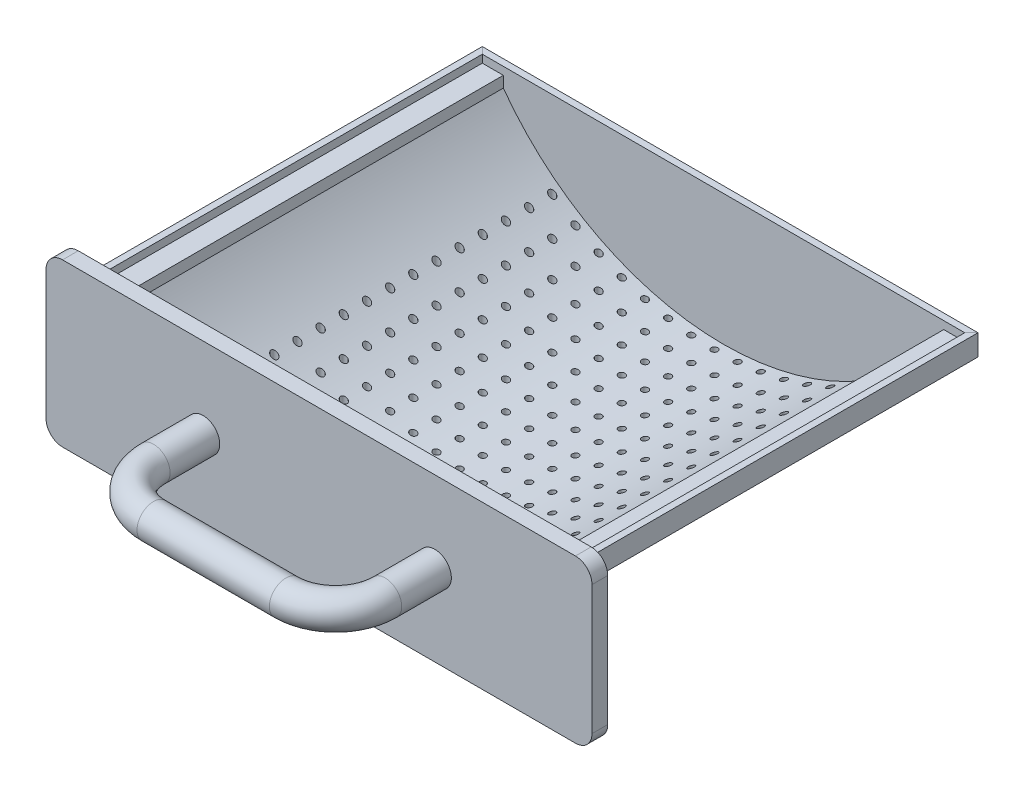
from build123d import *

# Parameters (mm, degrees)
RESSALTO_EXTRUS_O1_DEPTH = 4.75
ESBO_O2_R                = 5
ESBO_O8_W                = 137.1
ESBO_O8_H                = 4.35
CORTE_EXTRUS_O1_DEPTH    = 40.65
RESSALTO_EXTRUS_O3_DEPTH = 119.5
RESSALTO_EXTRUS_O4_DEPTH = 2
ESBO_O11_R               = 1
CORTE_EXTRUS_O2_DEPTH    = 25.5


with BuildPart() as part:
    # Esboço1 → Ressalto-extrusão1 (new body)
    with BuildSketch(Plane.XY):
        with BuildLine():
            Line((77.5, -24.5), (-77.5, -24.5))
            ThreePointArc((-77.5, -24.5), (-81.035533906, -23.035533906), (-82.5, -19.5))
            Line((-82.5, -19.5), (-82.5, 19.5))
            ThreePointArc((-82.5, 19.5), (-81.035533906, 23.035533906), (-77.5, 24.5))
            Line((-77.5, 24.5), (77.5, 24.5))
            ThreePointArc((77.5, 24.5), (81.035533906, 23.035533906), (82.5, 19.5))
            Line((82.5, 19.5), (82.5, -19.5))
            ThreePointArc((82.5, -19.5), (81.035533906, -23.035533906), (77.5, -24.5))
        make_face()
    extrude(amount=RESSALTO_EXTRUS_O1_DEPTH)

    # Varredura1: sweep along a path in Esboço3
    with BuildLine(Plane(origin=(0, 0, 0), x_dir=(1, 0, 0), z_dir=(0, 1, 0))) as varredura1_path:
        Line((-35, -4.75), (-35, -19.75))
        ThreePointArc((-35, -19.75), (-30.606601718, -30.356601718), (-20, -34.75))
        Line((-20, -34.75), (20, -34.75))
        ThreePointArc((20, -34.75), (30.606601718, -30.356601718), (35, -19.75))
        Line((35, -19.75), (35, -4.75))
    # Esboço2 → Varredura1 (sweep)
    with BuildSketch(Plane.XY.offset(4.75)):
        with Locations((-35, 0)):
            Circle(ESBO_O2_R)
    sweep(path=varredura1_path.line)

    # Varredura2: sweep along a path in Esboço6
    with BuildLine(Plane(origin=(0, 0, 0), x_dir=(1, 0, 0), z_dir=(0, 1, 0))) as varredura2_path:
        Line((74, 0), (74, 118.6))
        Line((74, 118.6), (-74, 118.6))
        Line((-74, 118.6), (-74, 0))
    # Esboço4 → Varredura2 (sweep)
    with BuildSketch(Plane(origin=(0, 0, 0), x_dir=(-1, 0, 0), z_dir=(0, 0, -1))):
        Polygon((-74.9, 19.5), (-74.9, 13.15), (-68.55, 13.15), (-68.55, 15.15), (-72.9, 15.15), (-72.9, 19.5), align=None)
    sweep(path=varredura2_path.line, transition=Transition.RIGHT)

    # Esboço8 → Corte-extrusão1 (cut, through all)
    with BuildSketch(Plane(origin=(0, 15.15, 0), x_dir=(1, 0, 0), z_dir=(0, 1, 0))):
        with Locations((0, 115.325)):
            Rectangle(ESBO_O8_W, ESBO_O8_H)
    extrude(amount=-CORTE_EXTRUS_O1_DEPTH, mode=Mode.SUBTRACT)

    # Esboço7 → Ressalto-extrusão3 (add)
    with BuildSketch(Plane(origin=(0, 0, 0), x_dir=(-1, 0, 0), z_dir=(0, 0, -1))):
        with BuildLine():
            Line((-68.55, 15.15), (-72.9, 15.15))
            Line((-72.9, 15.15), (-72.9, 17.15))
            Line((-72.9, 17.15), (-66.55, 17.15))
            Line((-66.55, 17.15), (-66.55, 13.798432938))
            ThreePointArc((-66.55, 13.798432938), (0, -20), (66.55, 13.798432938))
            Line((66.55, 13.798432938), (66.55, 17.15))
            Line((66.55, 17.15), (72.9, 17.15))
            Line((72.9, 17.15), (72.9, 15.15))
            Line((72.9, 15.15), (68.55, 15.15))
            Line((68.55, 15.15), (68.55, 13.15))
            ThreePointArc((68.55, 13.15), (0, -22), (-68.55, 13.15))
            Line((-68.55, 13.15), (-68.55, 15.15))
        make_face()
    extrude(amount=RESSALTO_EXTRUS_O3_DEPTH)

    # Esboço10 → Ressalto-extrusão4 (add)
    with BuildSketch(Plane(origin=(0, 0, -119.5), x_dir=(-1, 0, 0), z_dir=(0, 0, -1))):
        with BuildLine():
            Line((-66.071387505, 13.15), (66.071387505, 13.15))
            ThreePointArc((66.071387505, 13.15), (0, -20), (-66.071387505, 13.15))
        make_face()
    extrude(amount=-RESSALTO_EXTRUS_O4_DEPTH)

    # Esboço11 → Corte-extrusão2 (cut, through all)
    with BuildSketch(Plane(origin=(0, 0, 0), x_dir=(1, 0, 0), z_dir=(0, 1, 0))):
        with Locations(Location((0, 58.75, 0), (0, 0, 270))):
            Circle(ESBO_O11_R)
        with Locations(Location((-7, 58.75, 0), (0, 0, 270))):
            Circle(ESBO_O11_R)
        with Locations(Location((-14, 58.75, 0), (0, 0, 270))):
            Circle(ESBO_O11_R)
        with Locations(Location((-21, 58.75, 0), (0, 0, 270))):
            Circle(ESBO_O11_R)
        with Locations(Location((-28, 58.75, 0), (0, 0, 270))):
            Circle(ESBO_O11_R)
        with Locations(Location((-35, 58.75, 0), (0, 0, 270))):
            Circle(ESBO_O11_R)
        with Locations(Location((-42, 58.75, 0), (0, 0, 270))):
            Circle(ESBO_O11_R)
        with Locations(Location((-49, 58.75, 0), (0, 0, 270))):
            Circle(ESBO_O11_R)
        with Locations((-56, 58.75)):
            Circle(ESBO_O11_R)
        with Locations((-63, 58.75)):
            Circle(ESBO_O11_R)
        with Locations(Location((-7, 65.75, 0), (0, 0, 270))):
            Circle(ESBO_O11_R)
        with Locations(Location((-14, 65.75, 0), (0, 0, 270))):
            Circle(ESBO_O11_R)
        with Locations(Location((-21, 65.75, 0), (0, 0, 270))):
            Circle(ESBO_O11_R)
        with Locations(Location((-28, 65.75, 0), (0, 0, 270))):
            Circle(ESBO_O11_R)
        with Locations(Location((-35, 65.75, 0), (0, 0, 270))):
            Circle(ESBO_O11_R)
        with Locations(Location((-42, 65.75, 0), (0, 0, 270))):
            Circle(ESBO_O11_R)
        with Locations(Location((-49, 65.75, 0), (0, 0, 270))):
            Circle(ESBO_O11_R)
        with Locations((-56, 65.75)):
            Circle(ESBO_O11_R)
        with Locations((-63, 65.75)):
            Circle(ESBO_O11_R)
        with Locations(Location((-7, 72.75, 0), (0, 0, 270))):
            Circle(ESBO_O11_R)
        with Locations(Location((-14, 72.75, 0), (0, 0, 270))):
            Circle(ESBO_O11_R)
        with Locations(Location((-21, 72.75, 0), (0, 0, 270))):
            Circle(ESBO_O11_R)
        with Locations(Location((-28, 72.75, 0), (0, 0, 270))):
            Circle(ESBO_O11_R)
        with Locations(Location((-35, 72.75, 0), (0, 0, 270))):
            Circle(ESBO_O11_R)
        with Locations(Location((-42, 72.75, 0), (0, 0, 270))):
            Circle(ESBO_O11_R)
        with Locations(Location((-49, 72.75, 0), (0, 0, 270))):
            Circle(ESBO_O11_R)
        with Locations((-56, 72.75)):
            Circle(ESBO_O11_R)
        with Locations((-63, 72.75)):
            Circle(ESBO_O11_R)
        with Locations(Location((-7, 79.75, 0), (0, 0, 270))):
            Circle(ESBO_O11_R)
        with Locations(Location((-14, 79.75, 0), (0, 0, 270))):
            Circle(ESBO_O11_R)
        with Locations(Location((-21, 79.75, 0), (0, 0, 270))):
            Circle(ESBO_O11_R)
        with Locations(Location((-28, 79.75, 0), (0, 0, 270))):
            Circle(ESBO_O11_R)
        with Locations(Location((-35, 79.75, 0), (0, 0, 270))):
            Circle(ESBO_O11_R)
        with Locations(Location((-42, 79.75, 0), (0, 0, 270))):
            Circle(ESBO_O11_R)
        with Locations(Location((-49, 79.75, 0), (0, 0, 270))):
            Circle(ESBO_O11_R)
        with Locations((-56, 79.75)):
            Circle(ESBO_O11_R)
        with Locations((-63, 79.75)):
            Circle(ESBO_O11_R)
        with Locations(Location((-7, 86.75, 0), (0, 0, 270))):
            Circle(ESBO_O11_R)
        with Locations(Location((-14, 86.75, 0), (0, 0, 270))):
            Circle(ESBO_O11_R)
        with Locations(Location((-21, 86.75, 0), (0, 0, 270))):
            Circle(ESBO_O11_R)
        with Locations(Location((-28, 86.75, 0), (0, 0, 270))):
            Circle(ESBO_O11_R)
        with Locations(Location((-35, 86.75, 0), (0, 0, 270))):
            Circle(ESBO_O11_R)
        with Locations(Location((-42, 86.75, 0), (0, 0, 270))):
            Circle(ESBO_O11_R)
        with Locations(Location((-49, 86.75, 0), (0, 0, 270))):
            Circle(ESBO_O11_R)
        with Locations((-56, 86.75)):
            Circle(ESBO_O11_R)
        with Locations((-63, 86.75)):
            Circle(ESBO_O11_R)
        with Locations(Location((-7, 93.75, 0), (0, 0, 270))):
            Circle(ESBO_O11_R)
        with Locations(Location((-14, 93.75, 0), (0, 0, 270))):
            Circle(ESBO_O11_R)
        with Locations(Location((-21, 93.75, 0), (0, 0, 270))):
            Circle(ESBO_O11_R)
        with Locations(Location((-28, 93.75, 0), (0, 0, 270))):
            Circle(ESBO_O11_R)
        with Locations(Location((-35, 93.75, 0), (0, 0, 270))):
            Circle(ESBO_O11_R)
        with Locations(Location((-42, 93.75, 0), (0, 0, 270))):
            Circle(ESBO_O11_R)
        with Locations(Location((-49, 93.75, 0), (0, 0, 270))):
            Circle(ESBO_O11_R)
        with Locations((-56, 93.75)):
            Circle(ESBO_O11_R)
        with Locations((-63, 93.75)):
            Circle(ESBO_O11_R)
        with Locations(Location((-7, 100.75, 0), (0, 0, 270))):
            Circle(ESBO_O11_R)
        with Locations(Location((-14, 100.75, 0), (0, 0, 270))):
            Circle(ESBO_O11_R)
        with Locations(Location((-21, 100.75, 0), (0, 0, 270))):
            Circle(ESBO_O11_R)
        with Locations(Location((-28, 100.75, 0), (0, 0, 270))):
            Circle(ESBO_O11_R)
        with Locations(Location((-35, 100.75, 0), (0, 0, 270))):
            Circle(ESBO_O11_R)
        with Locations(Location((-42, 100.75, 0), (0, 0, 270))):
            Circle(ESBO_O11_R)
        with Locations(Location((-49, 100.75, 0), (0, 0, 270))):
            Circle(ESBO_O11_R)
        with Locations((-56, 100.75)):
            Circle(ESBO_O11_R)
        with Locations((-63, 100.75)):
            Circle(ESBO_O11_R)
        with Locations(Location((-7, 107.75, 0), (0, 0, 270))):
            Circle(ESBO_O11_R)
        with Locations(Location((-14, 107.75, 0), (0, 0, 270))):
            Circle(ESBO_O11_R)
        with Locations(Location((-21, 107.75, 0), (0, 0, 270))):
            Circle(ESBO_O11_R)
        with Locations(Location((-28, 107.75, 0), (0, 0, 270))):
            Circle(ESBO_O11_R)
        with Locations(Location((-35, 107.75, 0), (0, 0, 270))):
            Circle(ESBO_O11_R)
        with Locations(Location((-42, 107.75, 0), (0, 0, 270))):
            Circle(ESBO_O11_R)
        with Locations(Location((-49, 107.75, 0), (0, 0, 270))):
            Circle(ESBO_O11_R)
        with Locations((-56, 107.75)):
            Circle(ESBO_O11_R)
        with Locations((-63, 107.75)):
            Circle(ESBO_O11_R)
        with Locations(Location((-7, 114.75, 0), (0, 0, 270))):
            Circle(ESBO_O11_R)
        with Locations(Location((-14, 114.75, 0), (0, 0, 270))):
            Circle(ESBO_O11_R)
        with Locations(Location((-21, 114.75, 0), (0, 0, 270))):
            Circle(ESBO_O11_R)
        with Locations(Location((-28, 114.75, 0), (0, 0, 270))):
            Circle(ESBO_O11_R)
        with Locations(Location((-35, 114.75, 0), (0, 0, 270))):
            Circle(ESBO_O11_R)
        with Locations(Location((-42, 114.75, 0), (0, 0, 270))):
            Circle(ESBO_O11_R)
        with Locations(Location((-49, 114.75, 0), (0, 0, 270))):
            Circle(ESBO_O11_R)
        with Locations((-56, 114.75)):
            Circle(ESBO_O11_R)
        with Locations((-63, 114.75)):
            Circle(ESBO_O11_R)
        with Locations(Location((0, 65.75, 0), (0, 0, 270))):
            Circle(ESBO_O11_R)
        with Locations(Location((0, 72.75, 0), (0, 0, 270))):
            Circle(ESBO_O11_R)
        with Locations(Location((0, 79.75, 0), (0, 0, 270))):
            Circle(ESBO_O11_R)
        with Locations(Location((0, 86.75, 0), (0, 0, 270))):
            Circle(ESBO_O11_R)
        with Locations(Location((0, 93.75, 0), (0, 0, 270))):
            Circle(ESBO_O11_R)
        with Locations(Location((0, 100.75, 0), (0, 0, 270))):
            Circle(ESBO_O11_R)
        with Locations(Location((0, 107.75, 0), (0, 0, 270))):
            Circle(ESBO_O11_R)
        with Locations(Location((0, 114.75, 0), (0, 0, 270))):
            Circle(ESBO_O11_R)
        with Locations(Location((0, 2.75, 0), (0, 0, 270))):
            Circle(ESBO_O11_R)
        with Locations((-63, 2.75)):
            Circle(ESBO_O11_R)
        with Locations((-56, 2.75)):
            Circle(ESBO_O11_R)
        with Locations(Location((-49, 2.75, 0), (0, 0, 270))):
            Circle(ESBO_O11_R)
        with Locations(Location((-42, 2.75, 0), (0, 0, 270))):
            Circle(ESBO_O11_R)
        with Locations(Location((-35, 2.75, 0), (0, 0, 270))):
            Circle(ESBO_O11_R)
        with Locations(Location((-28, 2.75, 0), (0, 0, 270))):
            Circle(ESBO_O11_R)
        with Locations(Location((-21, 2.75, 0), (0, 0, 270))):
            Circle(ESBO_O11_R)
        with Locations(Location((-14, 2.75, 0), (0, 0, 270))):
            Circle(ESBO_O11_R)
        with Locations(Location((-7, 2.75, 0), (0, 0, 270))):
            Circle(ESBO_O11_R)
        with Locations(Location((0, 9.75, 0), (0, 0, 270))):
            Circle(ESBO_O11_R)
        with Locations(Location((0, 16.75, 0), (0, 0, 270))):
            Circle(ESBO_O11_R)
        with Locations(Location((0, 23.75, 0), (0, 0, 270))):
            Circle(ESBO_O11_R)
        with Locations(Location((0, 30.75, 0), (0, 0, 270))):
            Circle(ESBO_O11_R)
        with Locations(Location((0, 37.75, 0), (0, 0, 270))):
            Circle(ESBO_O11_R)
        with Locations(Location((0, 44.75, 0), (0, 0, 270))):
            Circle(ESBO_O11_R)
        with Locations(Location((0, 51.75, 0), (0, 0, 270))):
            Circle(ESBO_O11_R)
        with Locations((-63, 9.75)):
            Circle(ESBO_O11_R)
        with Locations((-56, 9.75)):
            Circle(ESBO_O11_R)
        with Locations(Location((-49, 9.75, 0), (0, 0, 270))):
            Circle(ESBO_O11_R)
        with Locations(Location((-42, 9.75, 0), (0, 0, 270))):
            Circle(ESBO_O11_R)
        with Locations(Location((-35, 9.75, 0), (0, 0, 270))):
            Circle(ESBO_O11_R)
        with Locations(Location((-28, 9.75, 0), (0, 0, 270))):
            Circle(ESBO_O11_R)
        with Locations(Location((-21, 9.75, 0), (0, 0, 270))):
            Circle(ESBO_O11_R)
        with Locations(Location((-14, 9.75, 0), (0, 0, 270))):
            Circle(ESBO_O11_R)
        with Locations(Location((-7, 9.75, 0), (0, 0, 270))):
            Circle(ESBO_O11_R)
        with Locations((-63, 16.75)):
            Circle(ESBO_O11_R)
        with Locations((-56, 16.75)):
            Circle(ESBO_O11_R)
        with Locations(Location((-49, 16.75, 0), (0, 0, 270))):
            Circle(ESBO_O11_R)
        with Locations(Location((-42, 16.75, 0), (0, 0, 270))):
            Circle(ESBO_O11_R)
        with Locations(Location((-35, 16.75, 0), (0, 0, 270))):
            Circle(ESBO_O11_R)
        with Locations(Location((-28, 16.75, 0), (0, 0, 270))):
            Circle(ESBO_O11_R)
        with Locations(Location((-21, 16.75, 0), (0, 0, 270))):
            Circle(ESBO_O11_R)
        with Locations(Location((-14, 16.75, 0), (0, 0, 270))):
            Circle(ESBO_O11_R)
        with Locations(Location((-7, 16.75, 0), (0, 0, 270))):
            Circle(ESBO_O11_R)
        with Locations((-63, 23.75)):
            Circle(ESBO_O11_R)
        with Locations((-56, 23.75)):
            Circle(ESBO_O11_R)
        with Locations(Location((-49, 23.75, 0), (0, 0, 270))):
            Circle(ESBO_O11_R)
        with Locations(Location((-42, 23.75, 0), (0, 0, 270))):
            Circle(ESBO_O11_R)
        with Locations(Location((-35, 23.75, 0), (0, 0, 270))):
            Circle(ESBO_O11_R)
        with Locations(Location((-28, 23.75, 0), (0, 0, 270))):
            Circle(ESBO_O11_R)
        with Locations(Location((-21, 23.75, 0), (0, 0, 270))):
            Circle(ESBO_O11_R)
        with Locations(Location((-14, 23.75, 0), (0, 0, 270))):
            Circle(ESBO_O11_R)
        with Locations(Location((-7, 23.75, 0), (0, 0, 270))):
            Circle(ESBO_O11_R)
        with Locations((-63, 30.75)):
            Circle(ESBO_O11_R)
        with Locations((-56, 30.75)):
            Circle(ESBO_O11_R)
        with Locations(Location((-49, 30.75, 0), (0, 0, 270))):
            Circle(ESBO_O11_R)
        with Locations(Location((-42, 30.75, 0), (0, 0, 270))):
            Circle(ESBO_O11_R)
        with Locations(Location((-35, 30.75, 0), (0, 0, 270))):
            Circle(ESBO_O11_R)
        with Locations(Location((-28, 30.75, 0), (0, 0, 270))):
            Circle(ESBO_O11_R)
        with Locations(Location((-21, 30.75, 0), (0, 0, 270))):
            Circle(ESBO_O11_R)
        with Locations(Location((-14, 30.75, 0), (0, 0, 270))):
            Circle(ESBO_O11_R)
        with Locations(Location((-7, 30.75, 0), (0, 0, 270))):
            Circle(ESBO_O11_R)
        with Locations((-63, 37.75)):
            Circle(ESBO_O11_R)
        with Locations((-56, 37.75)):
            Circle(ESBO_O11_R)
        with Locations(Location((-49, 37.75, 0), (0, 0, 270))):
            Circle(ESBO_O11_R)
        with Locations(Location((-42, 37.75, 0), (0, 0, 270))):
            Circle(ESBO_O11_R)
        with Locations(Location((-35, 37.75, 0), (0, 0, 270))):
            Circle(ESBO_O11_R)
        with Locations(Location((-28, 37.75, 0), (0, 0, 270))):
            Circle(ESBO_O11_R)
        with Locations(Location((-21, 37.75, 0), (0, 0, 270))):
            Circle(ESBO_O11_R)
        with Locations(Location((-14, 37.75, 0), (0, 0, 270))):
            Circle(ESBO_O11_R)
        with Locations(Location((-7, 37.75, 0), (0, 0, 270))):
            Circle(ESBO_O11_R)
        with Locations((-63, 44.75)):
            Circle(ESBO_O11_R)
        with Locations((-56, 44.75)):
            Circle(ESBO_O11_R)
        with Locations(Location((-49, 44.75, 0), (0, 0, 270))):
            Circle(ESBO_O11_R)
        with Locations(Location((-42, 44.75, 0), (0, 0, 270))):
            Circle(ESBO_O11_R)
        with Locations(Location((-35, 44.75, 0), (0, 0, 270))):
            Circle(ESBO_O11_R)
        with Locations(Location((-28, 44.75, 0), (0, 0, 270))):
            Circle(ESBO_O11_R)
        with Locations(Location((-21, 44.75, 0), (0, 0, 270))):
            Circle(ESBO_O11_R)
        with Locations(Location((-14, 44.75, 0), (0, 0, 270))):
            Circle(ESBO_O11_R)
        with Locations(Location((-7, 44.75, 0), (0, 0, 270))):
            Circle(ESBO_O11_R)
        with Locations((-63, 51.75)):
            Circle(ESBO_O11_R)
        with Locations((-56, 51.75)):
            Circle(ESBO_O11_R)
        with Locations(Location((-49, 51.75, 0), (0, 0, 270))):
            Circle(ESBO_O11_R)
        with Locations(Location((-42, 51.75, 0), (0, 0, 270))):
            Circle(ESBO_O11_R)
        with Locations(Location((-35, 51.75, 0), (0, 0, 270))):
            Circle(ESBO_O11_R)
        with Locations(Location((-28, 51.75, 0), (0, 0, 270))):
            Circle(ESBO_O11_R)
        with Locations(Location((-21, 51.75, 0), (0, 0, 270))):
            Circle(ESBO_O11_R)
        with Locations(Location((-14, 51.75, 0), (0, 0, 270))):
            Circle(ESBO_O11_R)
        with Locations(Location((-7, 51.75, 0), (0, 0, 270))):
            Circle(ESBO_O11_R)
        with Locations(Location((7, 51.75, 0), (0, 0, 270))):
            Circle(ESBO_O11_R)
        with Locations(Location((14, 51.75, 0), (0, 0, 270))):
            Circle(ESBO_O11_R)
        with Locations(Location((21, 51.75, 0), (0, 0, 270))):
            Circle(ESBO_O11_R)
        with Locations(Location((28, 51.75, 0), (0, 0, 270))):
            Circle(ESBO_O11_R)
        with Locations(Location((35, 51.75, 0), (0, 0, 270))):
            Circle(ESBO_O11_R)
        with Locations(Location((42, 51.75, 0), (0, 0, 270))):
            Circle(ESBO_O11_R)
        with Locations(Location((49, 51.75, 0), (0, 0, 270))):
            Circle(ESBO_O11_R)
        with Locations((56, 51.75)):
            Circle(ESBO_O11_R)
        with Locations((63, 51.75)):
            Circle(ESBO_O11_R)
        with Locations(Location((7, 44.75, 0), (0, 0, 270))):
            Circle(ESBO_O11_R)
        with Locations(Location((14, 44.75, 0), (0, 0, 270))):
            Circle(ESBO_O11_R)
        with Locations(Location((21, 44.75, 0), (0, 0, 270))):
            Circle(ESBO_O11_R)
        with Locations(Location((28, 44.75, 0), (0, 0, 270))):
            Circle(ESBO_O11_R)
        with Locations(Location((35, 44.75, 0), (0, 0, 270))):
            Circle(ESBO_O11_R)
        with Locations(Location((42, 44.75, 0), (0, 0, 270))):
            Circle(ESBO_O11_R)
        with Locations(Location((49, 44.75, 0), (0, 0, 270))):
            Circle(ESBO_O11_R)
        with Locations((56, 44.75)):
            Circle(ESBO_O11_R)
        with Locations((63, 44.75)):
            Circle(ESBO_O11_R)
        with Locations(Location((7, 37.75, 0), (0, 0, 270))):
            Circle(ESBO_O11_R)
        with Locations(Location((14, 37.75, 0), (0, 0, 270))):
            Circle(ESBO_O11_R)
        with Locations(Location((21, 37.75, 0), (0, 0, 270))):
            Circle(ESBO_O11_R)
        with Locations(Location((28, 37.75, 0), (0, 0, 270))):
            Circle(ESBO_O11_R)
        with Locations(Location((35, 37.75, 0), (0, 0, 270))):
            Circle(ESBO_O11_R)
        with Locations(Location((42, 37.75, 0), (0, 0, 270))):
            Circle(ESBO_O11_R)
        with Locations(Location((49, 37.75, 0), (0, 0, 270))):
            Circle(ESBO_O11_R)
        with Locations((56, 37.75)):
            Circle(ESBO_O11_R)
        with Locations((63, 37.75)):
            Circle(ESBO_O11_R)
        with Locations(Location((7, 30.75, 0), (0, 0, 270))):
            Circle(ESBO_O11_R)
        with Locations(Location((14, 30.75, 0), (0, 0, 270))):
            Circle(ESBO_O11_R)
        with Locations(Location((21, 30.75, 0), (0, 0, 270))):
            Circle(ESBO_O11_R)
        with Locations(Location((28, 30.75, 0), (0, 0, 270))):
            Circle(ESBO_O11_R)
        with Locations(Location((35, 30.75, 0), (0, 0, 270))):
            Circle(ESBO_O11_R)
        with Locations(Location((42, 30.75, 0), (0, 0, 270))):
            Circle(ESBO_O11_R)
        with Locations(Location((49, 30.75, 0), (0, 0, 270))):
            Circle(ESBO_O11_R)
        with Locations((56, 30.75)):
            Circle(ESBO_O11_R)
        with Locations((63, 30.75)):
            Circle(ESBO_O11_R)
        with Locations(Location((7, 23.75, 0), (0, 0, 270))):
            Circle(ESBO_O11_R)
        with Locations(Location((14, 23.75, 0), (0, 0, 270))):
            Circle(ESBO_O11_R)
        with Locations(Location((21, 23.75, 0), (0, 0, 270))):
            Circle(ESBO_O11_R)
        with Locations(Location((28, 23.75, 0), (0, 0, 270))):
            Circle(ESBO_O11_R)
        with Locations(Location((35, 23.75, 0), (0, 0, 270))):
            Circle(ESBO_O11_R)
        with Locations(Location((42, 23.75, 0), (0, 0, 270))):
            Circle(ESBO_O11_R)
        with Locations(Location((49, 23.75, 0), (0, 0, 270))):
            Circle(ESBO_O11_R)
        with Locations((56, 23.75)):
            Circle(ESBO_O11_R)
        with Locations((63, 23.75)):
            Circle(ESBO_O11_R)
        with Locations(Location((7, 16.75, 0), (0, 0, 270))):
            Circle(ESBO_O11_R)
        with Locations(Location((14, 16.75, 0), (0, 0, 270))):
            Circle(ESBO_O11_R)
        with Locations(Location((21, 16.75, 0), (0, 0, 270))):
            Circle(ESBO_O11_R)
        with Locations(Location((28, 16.75, 0), (0, 0, 270))):
            Circle(ESBO_O11_R)
        with Locations(Location((35, 16.75, 0), (0, 0, 270))):
            Circle(ESBO_O11_R)
        with Locations(Location((42, 16.75, 0), (0, 0, 270))):
            Circle(ESBO_O11_R)
        with Locations(Location((49, 16.75, 0), (0, 0, 270))):
            Circle(ESBO_O11_R)
        with Locations((56, 16.75)):
            Circle(ESBO_O11_R)
        with Locations((63, 16.75)):
            Circle(ESBO_O11_R)
        with Locations(Location((7, 9.75, 0), (0, 0, 270))):
            Circle(ESBO_O11_R)
        with Locations(Location((14, 9.75, 0), (0, 0, 270))):
            Circle(ESBO_O11_R)
        with Locations(Location((21, 9.75, 0), (0, 0, 270))):
            Circle(ESBO_O11_R)
        with Locations(Location((28, 9.75, 0), (0, 0, 270))):
            Circle(ESBO_O11_R)
        with Locations(Location((35, 9.75, 0), (0, 0, 270))):
            Circle(ESBO_O11_R)
        with Locations(Location((42, 9.75, 0), (0, 0, 270))):
            Circle(ESBO_O11_R)
        with Locations(Location((49, 9.75, 0), (0, 0, 270))):
            Circle(ESBO_O11_R)
        with Locations((56, 9.75)):
            Circle(ESBO_O11_R)
        with Locations((63, 9.75)):
            Circle(ESBO_O11_R)
        with Locations(Location((7, 2.75, 0), (0, 0, 270))):
            Circle(ESBO_O11_R)
        with Locations(Location((14, 2.75, 0), (0, 0, 270))):
            Circle(ESBO_O11_R)
        with Locations(Location((21, 2.75, 0), (0, 0, 270))):
            Circle(ESBO_O11_R)
        with Locations(Location((28, 2.75, 0), (0, 0, 270))):
            Circle(ESBO_O11_R)
        with Locations(Location((35, 2.75, 0), (0, 0, 270))):
            Circle(ESBO_O11_R)
        with Locations(Location((42, 2.75, 0), (0, 0, 270))):
            Circle(ESBO_O11_R)
        with Locations(Location((49, 2.75, 0), (0, 0, 270))):
            Circle(ESBO_O11_R)
        with Locations((56, 2.75)):
            Circle(ESBO_O11_R)
        with Locations((63, 2.75)):
            Circle(ESBO_O11_R)
        with Locations((63, 114.75)):
            Circle(ESBO_O11_R)
        with Locations((56, 114.75)):
            Circle(ESBO_O11_R)
        with Locations(Location((49, 114.75, 0), (0, 0, 270))):
            Circle(ESBO_O11_R)
        with Locations(Location((42, 114.75, 0), (0, 0, 270))):
            Circle(ESBO_O11_R)
        with Locations(Location((35, 114.75, 0), (0, 0, 270))):
            Circle(ESBO_O11_R)
        with Locations(Location((28, 114.75, 0), (0, 0, 270))):
            Circle(ESBO_O11_R)
        with Locations(Location((21, 114.75, 0), (0, 0, 270))):
            Circle(ESBO_O11_R)
        with Locations(Location((14, 114.75, 0), (0, 0, 270))):
            Circle(ESBO_O11_R)
        with Locations(Location((7, 114.75, 0), (0, 0, 270))):
            Circle(ESBO_O11_R)
        with Locations((63, 107.75)):
            Circle(ESBO_O11_R)
        with Locations((56, 107.75)):
            Circle(ESBO_O11_R)
        with Locations(Location((49, 107.75, 0), (0, 0, 270))):
            Circle(ESBO_O11_R)
        with Locations(Location((42, 107.75, 0), (0, 0, 270))):
            Circle(ESBO_O11_R)
        with Locations(Location((35, 107.75, 0), (0, 0, 270))):
            Circle(ESBO_O11_R)
        with Locations(Location((28, 107.75, 0), (0, 0, 270))):
            Circle(ESBO_O11_R)
        with Locations(Location((21, 107.75, 0), (0, 0, 270))):
            Circle(ESBO_O11_R)
        with Locations(Location((14, 107.75, 0), (0, 0, 270))):
            Circle(ESBO_O11_R)
        with Locations(Location((7, 107.75, 0), (0, 0, 270))):
            Circle(ESBO_O11_R)
        with Locations((63, 100.75)):
            Circle(ESBO_O11_R)
        with Locations((56, 100.75)):
            Circle(ESBO_O11_R)
        with Locations(Location((49, 100.75, 0), (0, 0, 270))):
            Circle(ESBO_O11_R)
        with Locations(Location((42, 100.75, 0), (0, 0, 270))):
            Circle(ESBO_O11_R)
        with Locations(Location((35, 100.75, 0), (0, 0, 270))):
            Circle(ESBO_O11_R)
        with Locations(Location((28, 100.75, 0), (0, 0, 270))):
            Circle(ESBO_O11_R)
        with Locations(Location((21, 100.75, 0), (0, 0, 270))):
            Circle(ESBO_O11_R)
        with Locations(Location((14, 100.75, 0), (0, 0, 270))):
            Circle(ESBO_O11_R)
        with Locations(Location((7, 100.75, 0), (0, 0, 270))):
            Circle(ESBO_O11_R)
        with Locations((63, 93.75)):
            Circle(ESBO_O11_R)
        with Locations((56, 93.75)):
            Circle(ESBO_O11_R)
        with Locations(Location((49, 93.75, 0), (0, 0, 270))):
            Circle(ESBO_O11_R)
        with Locations(Location((42, 93.75, 0), (0, 0, 270))):
            Circle(ESBO_O11_R)
        with Locations(Location((35, 93.75, 0), (0, 0, 270))):
            Circle(ESBO_O11_R)
        with Locations(Location((28, 93.75, 0), (0, 0, 270))):
            Circle(ESBO_O11_R)
        with Locations(Location((21, 93.75, 0), (0, 0, 270))):
            Circle(ESBO_O11_R)
        with Locations(Location((14, 93.75, 0), (0, 0, 270))):
            Circle(ESBO_O11_R)
        with Locations(Location((7, 93.75, 0), (0, 0, 270))):
            Circle(ESBO_O11_R)
        with Locations((63, 86.75)):
            Circle(ESBO_O11_R)
        with Locations((56, 86.75)):
            Circle(ESBO_O11_R)
        with Locations(Location((49, 86.75, 0), (0, 0, 270))):
            Circle(ESBO_O11_R)
        with Locations(Location((42, 86.75, 0), (0, 0, 270))):
            Circle(ESBO_O11_R)
        with Locations(Location((35, 86.75, 0), (0, 0, 270))):
            Circle(ESBO_O11_R)
        with Locations(Location((28, 86.75, 0), (0, 0, 270))):
            Circle(ESBO_O11_R)
        with Locations(Location((21, 86.75, 0), (0, 0, 270))):
            Circle(ESBO_O11_R)
        with Locations(Location((14, 86.75, 0), (0, 0, 270))):
            Circle(ESBO_O11_R)
        with Locations(Location((7, 86.75, 0), (0, 0, 270))):
            Circle(ESBO_O11_R)
        with Locations((63, 79.75)):
            Circle(ESBO_O11_R)
        with Locations((56, 79.75)):
            Circle(ESBO_O11_R)
        with Locations(Location((49, 79.75, 0), (0, 0, 270))):
            Circle(ESBO_O11_R)
        with Locations(Location((42, 79.75, 0), (0, 0, 270))):
            Circle(ESBO_O11_R)
        with Locations(Location((35, 79.75, 0), (0, 0, 270))):
            Circle(ESBO_O11_R)
        with Locations(Location((28, 79.75, 0), (0, 0, 270))):
            Circle(ESBO_O11_R)
        with Locations(Location((21, 79.75, 0), (0, 0, 270))):
            Circle(ESBO_O11_R)
        with Locations(Location((14, 79.75, 0), (0, 0, 270))):
            Circle(ESBO_O11_R)
        with Locations(Location((7, 79.75, 0), (0, 0, 270))):
            Circle(ESBO_O11_R)
        with Locations((63, 72.75)):
            Circle(ESBO_O11_R)
        with Locations((56, 72.75)):
            Circle(ESBO_O11_R)
        with Locations(Location((49, 72.75, 0), (0, 0, 270))):
            Circle(ESBO_O11_R)
        with Locations(Location((42, 72.75, 0), (0, 0, 270))):
            Circle(ESBO_O11_R)
        with Locations(Location((35, 72.75, 0), (0, 0, 270))):
            Circle(ESBO_O11_R)
        with Locations(Location((28, 72.75, 0), (0, 0, 270))):
            Circle(ESBO_O11_R)
        with Locations(Location((21, 72.75, 0), (0, 0, 270))):
            Circle(ESBO_O11_R)
        with Locations(Location((14, 72.75, 0), (0, 0, 270))):
            Circle(ESBO_O11_R)
        with Locations(Location((7, 72.75, 0), (0, 0, 270))):
            Circle(ESBO_O11_R)
        with Locations((63, 65.75)):
            Circle(ESBO_O11_R)
        with Locations((56, 65.75)):
            Circle(ESBO_O11_R)
        with Locations(Location((49, 65.75, 0), (0, 0, 270))):
            Circle(ESBO_O11_R)
        with Locations(Location((42, 65.75, 0), (0, 0, 270))):
            Circle(ESBO_O11_R)
        with Locations(Location((35, 65.75, 0), (0, 0, 270))):
            Circle(ESBO_O11_R)
        with Locations(Location((28, 65.75, 0), (0, 0, 270))):
            Circle(ESBO_O11_R)
        with Locations(Location((21, 65.75, 0), (0, 0, 270))):
            Circle(ESBO_O11_R)
        with Locations(Location((14, 65.75, 0), (0, 0, 270))):
            Circle(ESBO_O11_R)
        with Locations(Location((7, 65.75, 0), (0, 0, 270))):
            Circle(ESBO_O11_R)
        with Locations((63, 58.75)):
            Circle(ESBO_O11_R)
        with Locations((56, 58.75)):
            Circle(ESBO_O11_R)
        with Locations(Location((49, 58.75, 0), (0, 0, 270))):
            Circle(ESBO_O11_R)
        with Locations(Location((42, 58.75, 0), (0, 0, 270))):
            Circle(ESBO_O11_R)
        with Locations(Location((35, 58.75, 0), (0, 0, 270))):
            Circle(ESBO_O11_R)
        with Locations(Location((28, 58.75, 0), (0, 0, 270))):
            Circle(ESBO_O11_R)
        with Locations(Location((21, 58.75, 0), (0, 0, 270))):
            Circle(ESBO_O11_R)
        with Locations(Location((14, 58.75, 0), (0, 0, 270))):
            Circle(ESBO_O11_R)
        with Locations(Location((7, 58.75, 0), (0, 0, 270))):
            Circle(ESBO_O11_R)
    extrude(amount=-CORTE_EXTRUS_O2_DEPTH, mode=Mode.SUBTRACT)


solid = part.part
